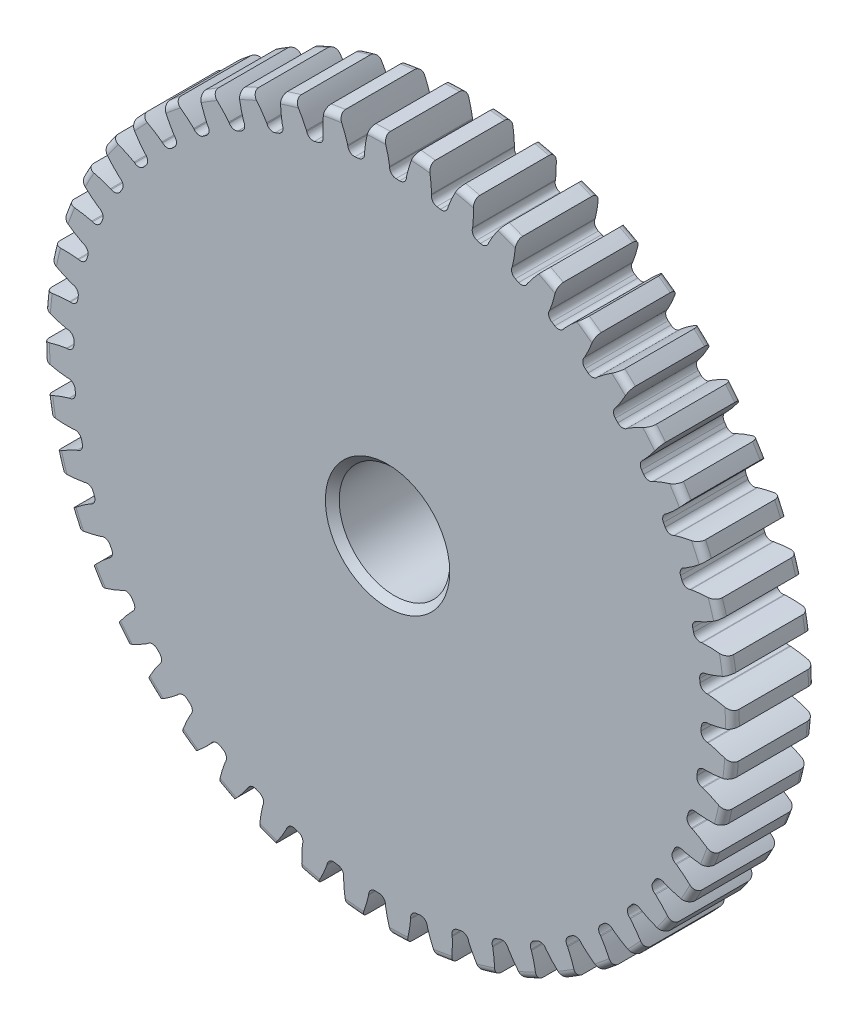
from build123d import *

# Parameters (mm, degrees)
SKETCH1_R                = 19.812
BOSS_EXTRUDE1_DEPTH      = 4.7625
SKETCH2_W                = 6.35
SKETCH2_H                = 7.9375
FILLET2_R                = 0.39624
CUT_EXTRUDE1_DEPTH       = 12.1125
FILLET1_R                = 0.37404675
CIRPATTERN1_COUNT        = 48
FILLET1_OF_CIRPATTERN1_R = 0.37404675
SKETCH5_R                = 3.175
CUT_EXTRUDE2_DEPTH       = 12.1125
CHAMFER1_SIZE            = 0.396875


with BuildPart() as part:
    # Sketch1 → Boss-Extrude1 (new body)
    with BuildSketch(Plane.XY):
        Circle(SKETCH1_R)
    extrude(amount=-BOSS_EXTRUDE1_DEPTH)

    # Sketch2 → Revolve1 (revolve)
    with BuildSketch(Plane(origin=(0, 0, 0), x_dir=(0, 0, -1), z_dir=(1, 0, 0))):
        with Locations((7.9375, 3.96875)):
            Rectangle(SKETCH2_W, SKETCH2_H)
    revolve(axis=Axis((0, 0, -4.7625), (0, 0, -1)))

    # Fillet2
    fillet2_edges = [part.edges().sort_by_distance(p)[0] for p in [
        (-19.812, 0, 0),
        (-19.812, 0, -4.7625),
        (0, -7.9375, -4.7625),
    ]]
    fillet(fillet2_edges, radius=FILLET2_R)

    # Sketch4 → Cut-Extrude1 (cut, through all)
    with BuildSketch(Plane.XY):
        with BuildLine():
            Line((0.119888881, 18.44282288), (0.119888881, 18.025663813))
            ThreePointArc((0.119888881, 18.025663813), (0.589797611, 18.016411075), (1.059305384, 17.994910429))
            Line((1.059305384, 17.994910429), (1.086588956, 18.411176322))
            add(Edge.make_bspline(
                [(3.349068074, 22.229097038), (1.567060397, 20.593176009), (1.086588956, 18.411176322)],
                knots=[0, 0, 0, 1, 1, 1], degree=2))
            ThreePointArc((3.349068074, 22.229097038), (0.735525691, 22.467933017), (-1.888041528, 22.400542656))
            add(Edge.make_bspline(
                [(-1.888041528, 22.400542656), (-0.216843888, 20.651575125), (0.119888881, 18.44282288)],
                knots=[0, 0, 0, 1, 1, 1], degree=2))
        make_face()
    cut_extrude1 = extrude(amount=-CUT_EXTRUDE1_DEPTH, mode=Mode.SUBTRACT)

    # Fillet1
    fillet1_edges = [part.edges().sort_by_distance(p)[0] for p in [
        (1.059305384, 17.994910429, -2.38125),
        (0.119888881, 18.025663813, -2.38125),
    ]]
    fillet(fillet1_edges, radius=FILLET1_R)

    # CirPattern1: Cut-Extrude1 ×48 about axis
    cirpattern1_axis = Axis((0, 0, -4.7625), (0, 0, 1))
    for i in range(1, CIRPATTERN1_COUNT):
        add(cut_extrude1.rotate(cirpattern1_axis, i * 360 / CIRPATTERN1_COUNT), mode=Mode.SUBTRACT)

    # Fillet1 of CirPattern1
    fillet1_of_cirpattern1_edges = [part.edges().sort_by_distance(p)[0] for p in [
        (-1.298564258, 17.979228574, -2.38125),
        (-2.233958045, 17.8871004, -2.38125),
        (-3.634215105, 17.655917133, -2.38125),
        (-4.549581329, 17.442483739, -2.38125),
        (-5.907683525, 17.030508055, -2.38125),
        (-6.787360016, 16.699421345, -2.38125),
        (-8.080069841, 16.113702263, -2.38125),
        (-8.90900509, 15.670627223, -2.38125),
        (-10.114203923, 14.921186557, -2.38125),
        (-10.878214618, 14.373704324, -2.38125),
        (-11.975281171, 13.473365212, -2.38125),
        (-12.661294877, 12.830843358, -2.38125),
        (-13.631458038, 11.795010853, -2.38125),
        (-14.227736871, 11.068443106, -2.38125),
        (-15.054396878, 9.914840588, -2.38125),
        (-15.550738342, 9.116658723, -2.38125),
        (-16.219750815, 7.865024651, -2.38125),
        (-16.607662369, 7.008885782, -2.38125),
        (-17.107580317, 5.680635963, -2.38125),
        (-17.380424688, 4.781188862, -2.38125),
        (-17.702694378, 3.399050018, -2.38125),
        (-17.855803121, 2.471684475, -2.38125),
        (-17.994910429, 1.059305384, -2.38125),
        (-18.025663813, 0.119888881, -2.38125),
        (-17.979228574, -1.298564258, -2.38125),
        (-17.8871004, -2.233958045, -2.38125),
        (-17.655917133, -3.634215105, -2.38125),
        (-17.442483739, -4.549581329, -2.38125),
        (-17.030508055, -5.907683525, -2.38125),
        (-16.699421345, -6.787360016, -2.38125),
        (-16.113702263, -8.080069841, -2.38125),
        (-15.670627223, -8.90900509, -2.38125),
        (-14.921186557, -10.114203923, -2.38125),
        (-14.373704324, -10.878214618, -2.38125),
        (-13.473365212, -11.975281171, -2.38125),
        (-12.830843358, -12.661294877, -2.38125),
        (-11.795010853, -13.631458038, -2.38125),
        (-11.068443106, -14.227736871, -2.38125),
        (-9.914840588, -15.054396878, -2.38125),
        (-9.116658723, -15.550738342, -2.38125),
        (-7.865024651, -16.219750815, -2.38125),
        (-7.008885782, -16.607662369, -2.38125),
        (-5.680635963, -17.107580317, -2.38125),
        (-4.781188862, -17.380424688, -2.38125),
        (-3.399050018, -17.702694378, -2.38125),
        (-2.471684475, -17.855803121, -2.38125),
        (-1.059305384, -17.994910429, -2.38125),
        (-0.119888881, -18.025663813, -2.38125),
        (1.298564258, -17.979228574, -2.38125),
        (2.233958045, -17.8871004, -2.38125),
        (3.634215105, -17.655917133, -2.38125),
        (4.549581329, -17.442483739, -2.38125),
        (5.907683525, -17.030508055, -2.38125),
        (6.787360016, -16.699421345, -2.38125),
        (8.080069841, -16.113702263, -2.38125),
        (8.90900509, -15.670627223, -2.38125),
        (10.114203923, -14.921186557, -2.38125),
        (10.878214618, -14.373704324, -2.38125),
        (11.975281171, -13.473365212, -2.38125),
        (12.661294877, -12.830843358, -2.38125),
        (13.631458038, -11.795010853, -2.38125),
        (14.227736871, -11.068443106, -2.38125),
        (15.054396878, -9.914840588, -2.38125),
        (15.550738342, -9.116658723, -2.38125),
        (16.219750815, -7.865024651, -2.38125),
        (16.607662369, -7.008885782, -2.38125),
        (17.107580317, -5.680635963, -2.38125),
        (17.380424688, -4.781188862, -2.38125),
        (17.702694378, -3.399050018, -2.38125),
        (17.855803121, -2.471684475, -2.38125),
        (17.994910429, -1.059305384, -2.38125),
        (18.025663813, -0.119888881, -2.38125),
        (17.979228574, 1.298564258, -2.38125),
        (17.8871004, 2.233958045, -2.38125),
        (17.655917133, 3.634215105, -2.38125),
        (17.442483739, 4.549581329, -2.38125),
        (17.030508055, 5.907683525, -2.38125),
        (16.699421345, 6.787360016, -2.38125),
        (16.113702263, 8.080069841, -2.38125),
        (15.670627223, 8.90900509, -2.38125),
        (14.921186557, 10.114203923, -2.38125),
        (14.373704324, 10.878214618, -2.38125),
        (13.473365212, 11.975281171, -2.38125),
        (12.830843358, 12.661294877, -2.38125),
        (11.795010853, 13.631458038, -2.38125),
        (11.068443106, 14.227736871, -2.38125),
        (9.914840588, 15.054396878, -2.38125),
        (9.116658723, 15.550738342, -2.38125),
        (7.865024651, 16.219750815, -2.38125),
        (7.008885782, 16.607662369, -2.38125),
        (5.680635963, 17.107580317, -2.38125),
        (4.781188862, 17.380424688, -2.38125),
        (3.399050018, 17.702694378, -2.38125),
        (2.471684475, 17.855803121, -2.38125),
    ]]
    fillet(fillet1_of_cirpattern1_edges, radius=FILLET1_OF_CIRPATTERN1_R)

    # Sketch5 → Cut-Extrude2 (cut, through all)
    with BuildSketch(Plane.XY):
        Circle(SKETCH5_R)
    extrude(amount=-CUT_EXTRUDE2_DEPTH, mode=Mode.SUBTRACT)

    # Chamfer1
    chamfer1_edges = [part.edges().sort_by_distance(p)[0] for p in [
        (-3.175, 0, -11.1125),
        (-3.175, 0, 0),
        (0, -7.9375, -11.1125),
    ]]
    chamfer(chamfer1_edges, length=CHAMFER1_SIZE)


solid = part.part
